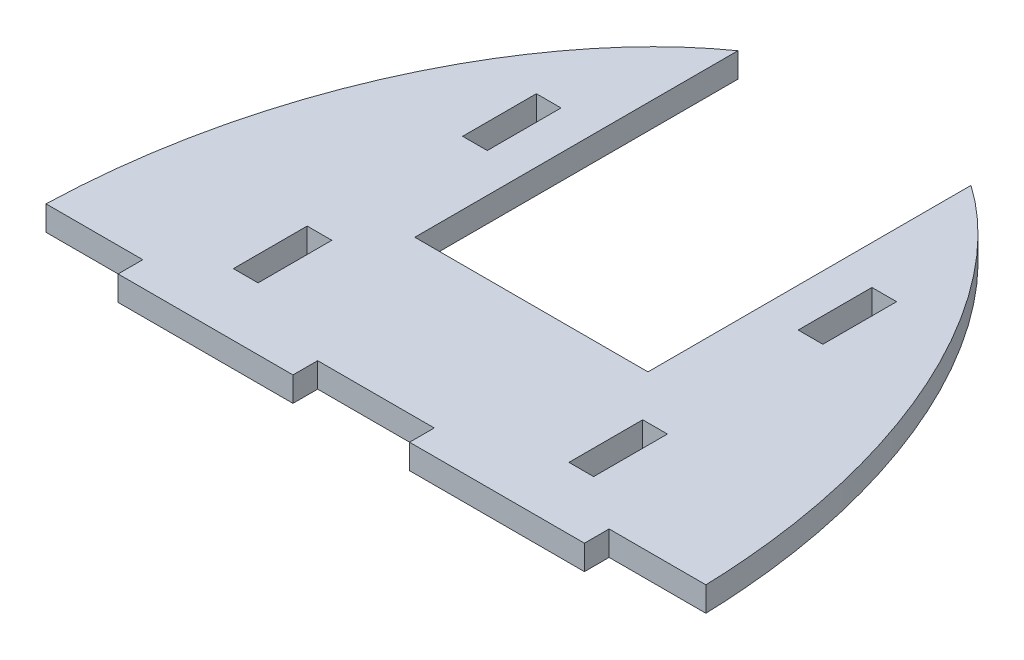
from build123d import *

# Parameters (mm, degrees)
BOSS_EXTRUDE1_DEPTH = 3.175
SKETCH2_W           = 3.175
SKETCH2_H           = 9.492
SKETCH2_W_2         = 12.5
SKETCH2_H_2         = 3.175
SKETCH2_W_3         = 15
SKETCH2_W_4         = 30
SKETCH2_H_3         = 55.059917187
CUT_EXTRUDE1_DEPTH  = 4.1750001


with BuildPart() as part:
    # Sketch1 → Boss-Extrude1 (new body)
    with BuildSketch(Plane(origin=(0, 0, 0), x_dir=(1, 0, 0), z_dir=(0, 1, 0))):
        with BuildLine():
            add(Edge.make_bspline(
                [(0, 0), (0, 36), (20.5, 67.166666667), (40.5, 70), (42.5, 70)],
                knots=[0, 0, 0, 0, 0.45, 0.5, 0.5, 0.5, 0.5], degree=3))
            Line((0, 0), (42.5, 0))
            Line((42.5, 0), (42.5, 70))
        make_face()
        with BuildLine():
            Line((42.5, 70), (42.5, 0))
            Line((42.5, 0), (85, 0))
            add(Edge.make_bspline(
                [(42.5, 70), (44.5, 70), (64.5, 67.166666667), (85, 36), (85, 0)],
                knots=[0.5, 0.5, 0.5, 0.5, 0.55, 1, 1, 1, 1], degree=3))
        make_face()
    extrude(amount=BOSS_EXTRUDE1_DEPTH)

    # Sketch2 → Cut-Extrude1 (cut, through all)
    with BuildSketch(Plane(origin=(0, 3.175, 0), x_dir=(1, 0, 0), z_dir=(0, 1, 0))):
        with Locations((20.9125, 42.246)):
            Rectangle(SKETCH2_W, SKETCH2_H)
        with Locations((64.0875, 42.246)):
            Rectangle(SKETCH2_W, SKETCH2_H)
        with Locations((20.9125, 12.754)):
            Rectangle(SKETCH2_W, SKETCH2_H)
        with Locations((64.0875, 12.754)):
            Rectangle(SKETCH2_W, SKETCH2_H)
        with Locations((6.25, 1.5875)):
            Rectangle(SKETCH2_W_2, SKETCH2_H_2)
        with Locations((42.5, 1.5875)):
            Rectangle(SKETCH2_W_3, SKETCH2_H_2)
        with Locations((78.75, 1.5875)):
            Rectangle(SKETCH2_W_2, SKETCH2_H_2)
        with Locations((42.5, 50.704958594)):
            Rectangle(SKETCH2_W_4, SKETCH2_H_3)
    extrude(amount=-CUT_EXTRUDE1_DEPTH, mode=Mode.SUBTRACT)


solid = part.part
